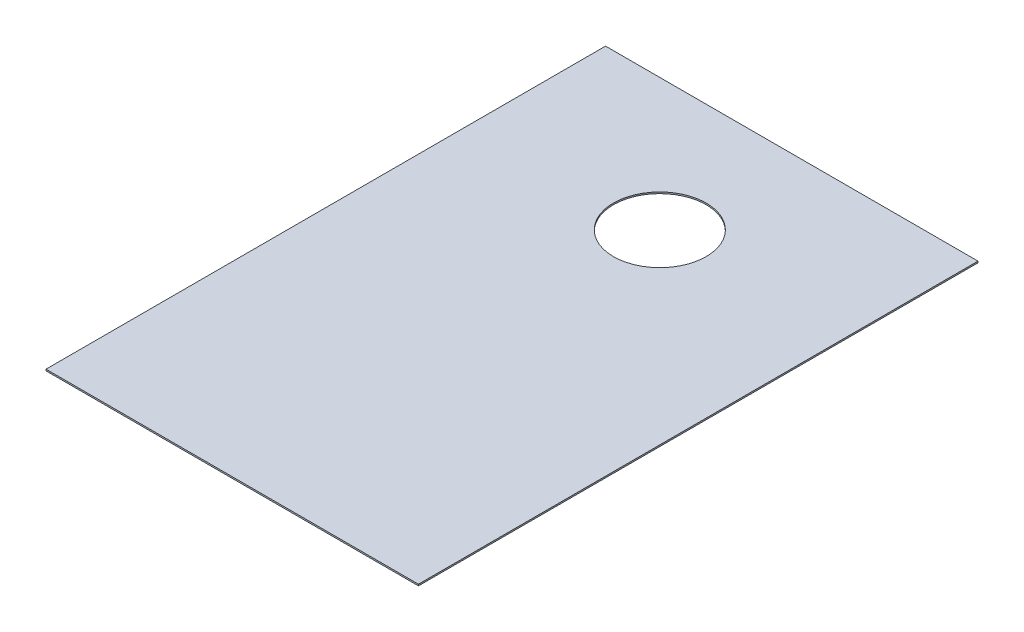
from build123d import *

# Parameters (mm, degrees)
SKETCH1_W           = 12.7
SKETCH1_H           = 19.08
BOSS_EXTRUDE1_DEPTH = 0.051
SKETCH2_R           = 1.58181762
CUT_EXTRUDE1_DEPTH  = 1.051


with BuildPart() as part:
    # Sketch1 → Boss-Extrude1 (new body)
    with BuildSketch(Plane(origin=(0, 0, 0), x_dir=(1, 0, 0), z_dir=(0, 1, 0))):
        Rectangle(SKETCH1_W, SKETCH1_H)
    extrude(amount=BOSS_EXTRUDE1_DEPTH)

    # Sketch2 → Cut-Extrude1 (cut, through all)
    with BuildSketch(Plane(origin=(0, 0.051, 0), x_dir=(1, 0, 0), z_dir=(0, 1, 0))):
        with Locations((0, 5.04)):
            Circle(SKETCH2_R)
    extrude(amount=-CUT_EXTRUDE1_DEPTH, mode=Mode.SUBTRACT)


solid = part.part
